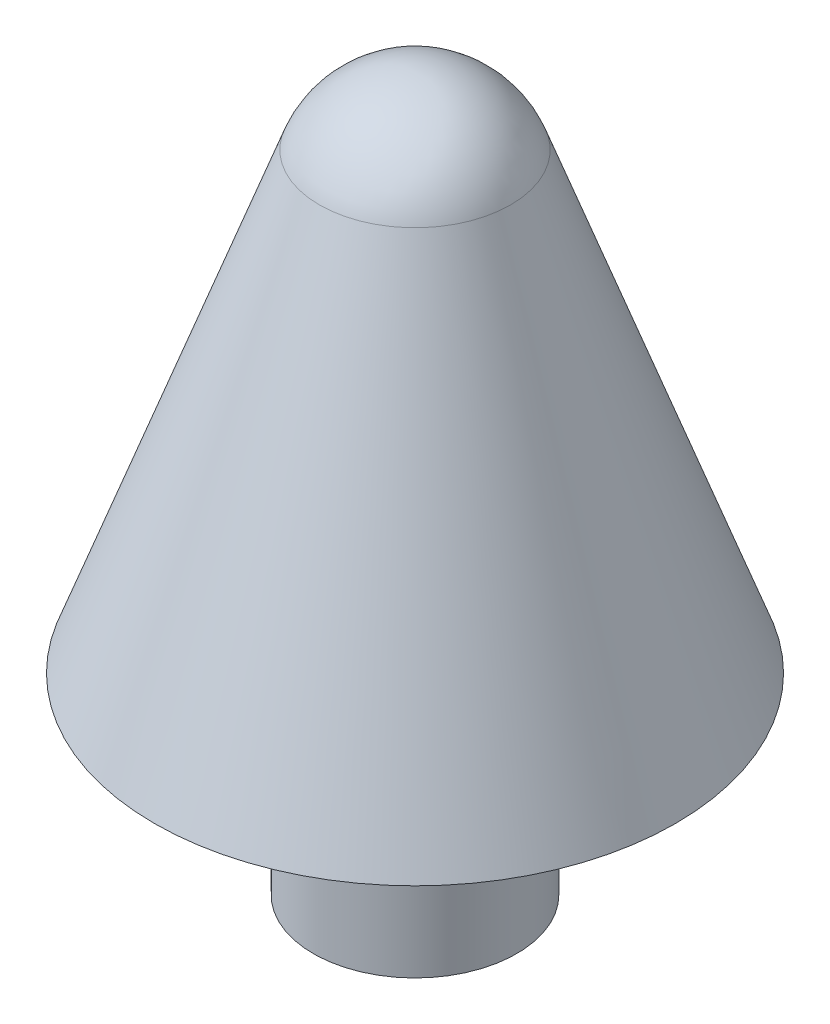
from build123d import *


with BuildPart() as part:
    # Sketch1 → Revolve1 (revolve)
    with BuildSketch(Plane.XY):
        with BuildLine():
            Line((0, 0), (3.175, 0))
            Line((3.175, 0), (3.175, 5.9944))
            Line((3.175, 5.9944), (8.130614218, 5.9944))
            Line((8.130614218, 5.9944), (2.983524071, 20.135913955))
            ThreePointArc((2.983524071, 20.135913955), (1.821105185, 21.650807741), (0, 22.225))
            Line((0, 22.225), (0, 0))
        make_face()
    revolve(axis=Axis((0, 22.225, 0), (0, -1, 0)))


solid = part.part
